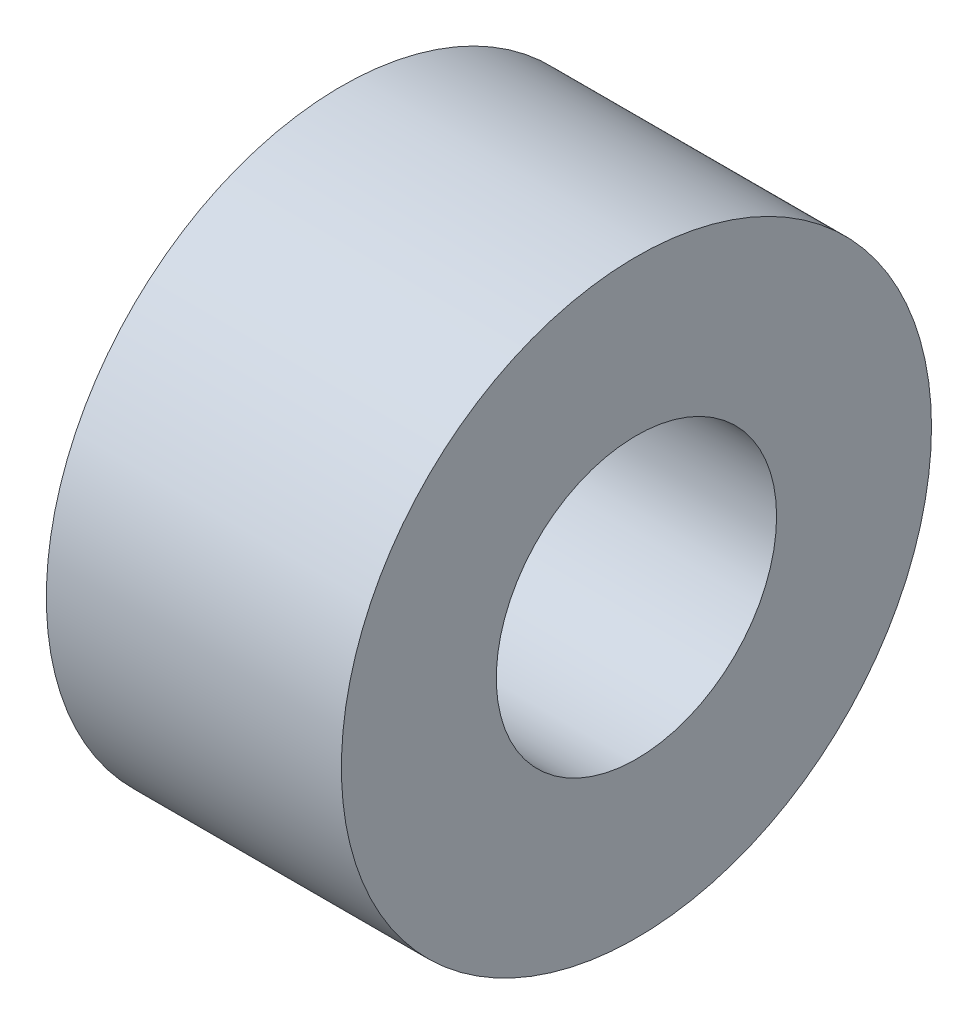
from build123d import *

# Parameters (mm, degrees)
SKETCH1_R           = 10
SKETCH1_R_2         = 4.75
BOSS_EXTRUDE1_DEPTH = 10


with BuildPart() as part:
    # Sketch1 → Boss-Extrude1 (new body)
    with BuildSketch(Plane(origin=(0, 0, 0), x_dir=(0, 0, -1), z_dir=(1, 0, 0))):
        Circle(SKETCH1_R)
        Circle(SKETCH1_R_2, mode=Mode.SUBTRACT)
    extrude(amount=BOSS_EXTRUDE1_DEPTH)


solid = part.part
